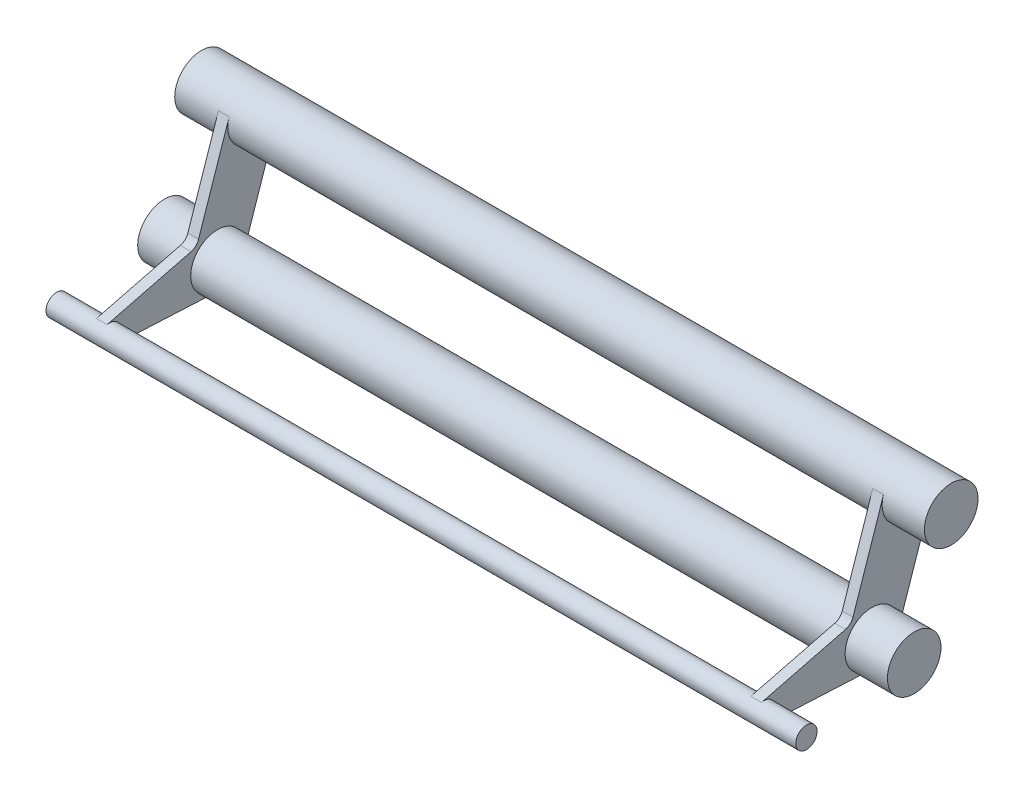
from build123d import *
from build123d.topology import SkipClean

# Parameters (mm, degrees)
CROQUIS1_R                = 5
SALIENTE_EXTRUIR6_DEPTH   = 120.2
SALIENTE_EXTRUIR6_2_DEPTH = 120.2
CROQUIS1_R_2              = 2
SALIENTE_EXTRUIR6_3_DEPTH = 120.2
SALIENTE_EXTRUIR8_DEPTH   = 2
SALIENTE_EXTRUIR9_DEPTH   = 2
SALIENTE_EXTRUIR10_DEPTH  = 7.9
CROQUIS14_R               = 5
CROQUIS14_R_2             = 2
SALIENTE_EXTRUIR11_DEPTH  = 7.9


with BuildPart() as part:
    # Croquis1 → Saliente-Extruir6 (new body)
    with BuildSketch(Plane(origin=(0, 0, 0), x_dir=(0, 0, -1), z_dir=(1, 0, 0))):
        Circle(CROQUIS1_R)
    extrude(amount=SALIENTE_EXTRUIR6_DEPTH)



with BuildPart() as body_2:
    # Croquis1 → Saliente-Extruir6 2 (new body)
    with BuildSketch(Plane(origin=(0, 0, 0), x_dir=(0, 0, -1), z_dir=(1, 0, 0))):
        with Locations((-6.915082, -20.579255)):
            Circle(CROQUIS1_R)
    extrude(amount=SALIENTE_EXTRUIR6_2_DEPTH)


with BuildPart() as body_3:
    # Croquis1 → Saliente-Extruir6 3 (new body)
    with BuildSketch(Plane(origin=(0, 0, 0), x_dir=(0, 0, -1), z_dir=(1, 0, 0))):
        with Locations((-27.035927, -22.579255)):
            Circle(CROQUIS1_R_2)
    extrude(amount=SALIENTE_EXTRUIR6_3_DEPTH)


with BuildPart() as part_1:
    with SkipClean():  # the faces are left unmerged after this step: merging them gives an invalid solid
        add(part.part)

        add(body_2.part)  # Saliente-Extruir8 merges body 2

        add(body_3.part)  # Saliente-Extruir8 merges body 3
        # Croquis10 → Saliente-Extruir8 (add)
        with BuildSketch(Plane.ZY):
            with BuildLine():
                Line((-4.73958, -1.592603), (2.175502, -22.171858))
                ThreePointArc((2.175502, -22.171858), (4.098509, -24.710467), (7.164198, -25.573045))
                Line((7.164198, -25.573045), (27.135573, -24.576771))
                ThreePointArc((27.135573, -24.576771), (29.026119, -22.777079), (27.526842, -20.64044))
                Line((27.526842, -20.64044), (11.843492, -16.669357))
                ThreePointArc((11.843492, -16.669357), (10.975071, -16.197582), (10.438575, -15.367583))
                Line((10.438575, -15.367583), (4.73958, 1.592603))
                ThreePointArc((4.73958, 1.592603), (-1.592603, 4.73958), (-4.73958, -1.592603))
            make_face()
        extrude(amount=SALIENTE_EXTRUIR8_DEPTH)

    # Croquis11 → Saliente-Extruir9 (add)
    with BuildSketch(Plane(origin=(120.2, 0, 0), x_dir=(0, 0, -1), z_dir=(1, 0, 0))):
        with BuildLine():
            Line((4.73958, -1.592603), (-2.175502, -22.171858))
            ThreePointArc((-2.175502, -22.171858), (-4.098509, -24.710467), (-7.164198, -25.573045))
            Line((-7.164198, -25.573045), (-27.135573, -24.576771))
            ThreePointArc((-27.135573, -24.576771), (-29.026119, -22.777079), (-27.526842, -20.64044))
            Line((-27.526842, -20.64044), (-11.843492, -16.669357))
            ThreePointArc((-11.843492, -16.669357), (-10.975071, -16.197582), (-10.438575, -15.367583))
            Line((-10.438575, -15.367583), (-4.73958, 1.592603))
            ThreePointArc((-4.73958, 1.592603), (1.592603, 4.73958), (4.73958, -1.592603))
        make_face()
    extrude(amount=SALIENTE_EXTRUIR9_DEPTH)

    # Croquis13 → Saliente-Extruir10 (add)
    with BuildSketch(Plane(origin=(122.2, 0, 0), x_dir=(0, 0, -1), z_dir=(1, 0, 0))):
        with BuildLine():
            ThreePointArc((-7.164198, -25.573045), (-4.098509, -24.710467), (-2.175502, -22.171858))
            ThreePointArc((-2.175502, -22.171858), (-1.980616, -21.386132), (-1.915082, -20.579255))
            ThreePointArc((-1.915082, -20.579255), (-10.361415, -16.956716), (-7.164198, -25.573045))
        make_face()
        with BuildLine():
            ThreePointArc((5, 0), (0.806877, 4.934465), (-4.73958, 1.592603))
            ThreePointArc((-4.73958, 1.592603), (-1.592603, -4.73958), (4.73958, -1.592603))
            ThreePointArc((4.73958, -1.592603), (4.934465, -0.806877), (5, 0))
        make_face()
        with BuildLine():
            ThreePointArc((-25.035927, -22.579255), (-25.807479, -21.000992), (-27.526842, -20.64044))
            ThreePointArc((-27.526842, -20.64044), (-29.026119, -22.777079), (-27.135573, -24.576771))
            ThreePointArc((-27.135573, -24.576771), (-25.657394, -24.028271), (-25.035927, -22.579255))
        make_face()
    extrude(amount=SALIENTE_EXTRUIR10_DEPTH)

    # Croquis14 → Saliente-Extruir11 (add)
    with BuildSketch(Plane.ZY.offset(2)):
        Circle(CROQUIS14_R)
        with Locations(Location((27.035927, -22.579255, 0), (0, 0, 180))):
            Circle(CROQUIS14_R_2)
        with Locations(Location((6.915082, -20.579255, 0), (0, 0, 180))):
            Circle(CROQUIS14_R)
    extrude(amount=SALIENTE_EXTRUIR11_DEPTH)


solid = part_1.part
